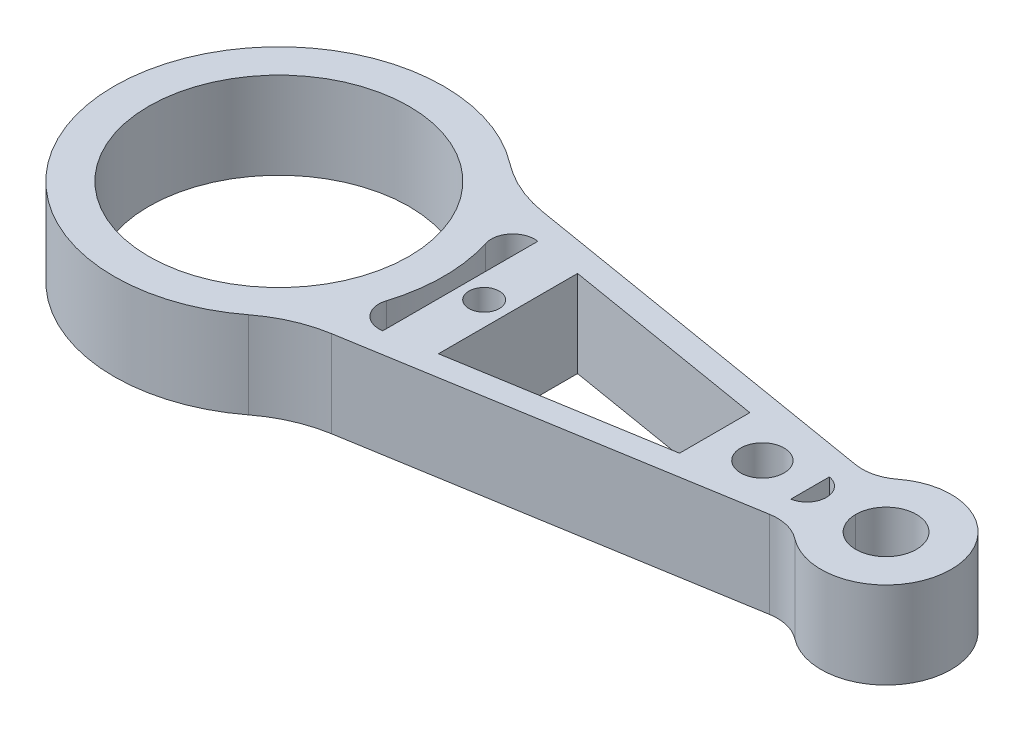
from build123d import *

# Parameters (mm, degrees)
SKETCH1_R           = 30
SKETCH1_R_2         = 7
BOSS_EXTRUDE1_DEPTH = 10
FILLET1_R           = 30
FILLET2_R           = 10
CUT_EXTRUDE1_DEPTH  = 21
BOSS_EXTRUDE2_DEPTH = 20
SKETCH4_R           = 3.5
SKETCH4_R_2         = 5
CUT_EXTRUDE2_DEPTH  = 21


with BuildPart() as part:
    # Sketch1 → Boss-Extrude1 (new body, symmetric)
    with BuildSketch(Plane(origin=(0, 0, 0), x_dir=(1, 0, 0), z_dir=(0, 1, 0))):
        with BuildLine():
            Line((27.935473676, 25.760615491), (128.063755469, 9.084385863))
            ThreePointArc((128.063755469, 9.084385863), (155, 0), (128.063755469, -9.084385863))
            Line((128.063755469, -9.084385863), (27.935473676, -25.760615491))
            ThreePointArc((27.935473676, -25.760615491), (-38, 0), (27.935473676, 25.760615491))
        make_face()
        Circle(SKETCH1_R, mode=Mode.SUBTRACT)
        with Locations((140, 0)):
            Circle(SKETCH1_R_2, mode=Mode.SUBTRACT)
    extrude(amount=BOSS_EXTRUDE1_DEPTH, both=True)

    # Fillet1
    fillet1_edges = [part.edges().sort_by_distance(p)[0] for p in [
        (27.935473676, 0, 25.760615491),
        (27.935473676, 0, -25.760615491),
    ]]
    fillet(fillet1_edges, radius=FILLET1_R)

    # Fillet2
    fillet2_edges = [part.edges().sort_by_distance(p)[0] for p in [
        (128.063755469, 0, 9.084385863),
        (128.063755469, 0, -9.084385863),
    ]]
    fillet(fillet2_edges, radius=FILLET2_R)

    # Sketch2 → Cut-Extrude1 (cut, through all)
    with BuildSketch(Plane(origin=(0, 10, 0), x_dir=(1, 0, 0), z_dir=(0, 1, 0))):
        with BuildLine():
            Line((41.828554558, 17.870982725), (122.478416149, 4.438857582))
            ThreePointArc((122.478416149, 4.438857582), (126.239130435, 0), (122.478416149, -4.438857582))
            Line((122.478416149, -4.438857582), (41.828554558, -17.870982725))
            ThreePointArc((41.828554558, -17.870982725), (37.231968897, -16.217361812), (36.238855523, -11.43439331))
            ThreePointArc((36.238855523, -11.43439331), (38, 0), (36.238855523, 11.43439331))
            ThreePointArc((36.238855523, 11.43439331), (37.231968897, 16.217361812), (41.828554558, 17.870982725))
        make_face()
    extrude(amount=-CUT_EXTRUDE1_DEPTH, mode=Mode.SUBTRACT)

    # Sketch3 → Boss-Extrude2 (add)
    with BuildSketch(Plane(origin=(0, 10, 0), x_dir=(1, 0, 0), z_dir=(0, 1, 0))):
        Polygon((100.478416149, 8.102927765), (122.478416149, 4.438857582), (122.478416149, -4.438857582), (100.478416149, -8.102927765), align=None)
        Polygon((41.828554558, 17.870982725), (52.828554558, 16.038947633), (52.828554558, -16.038947633), (41.828554558, -17.870982725), align=None)
    extrude(amount=-BOSS_EXTRUDE2_DEPTH)

    # Sketch4 → Cut-Extrude2 (cut, through all)
    with BuildSketch(Plane(origin=(0, 10, 0), x_dir=(1, 0, 0), z_dir=(0, 1, 0))):
        with Locations((47.328554558, 0)):
            Circle(SKETCH4_R)
        with Locations((111.478416149, 0)):
            Circle(SKETCH4_R_2)
    extrude(amount=-CUT_EXTRUDE2_DEPTH, mode=Mode.SUBTRACT)


solid = part.part
